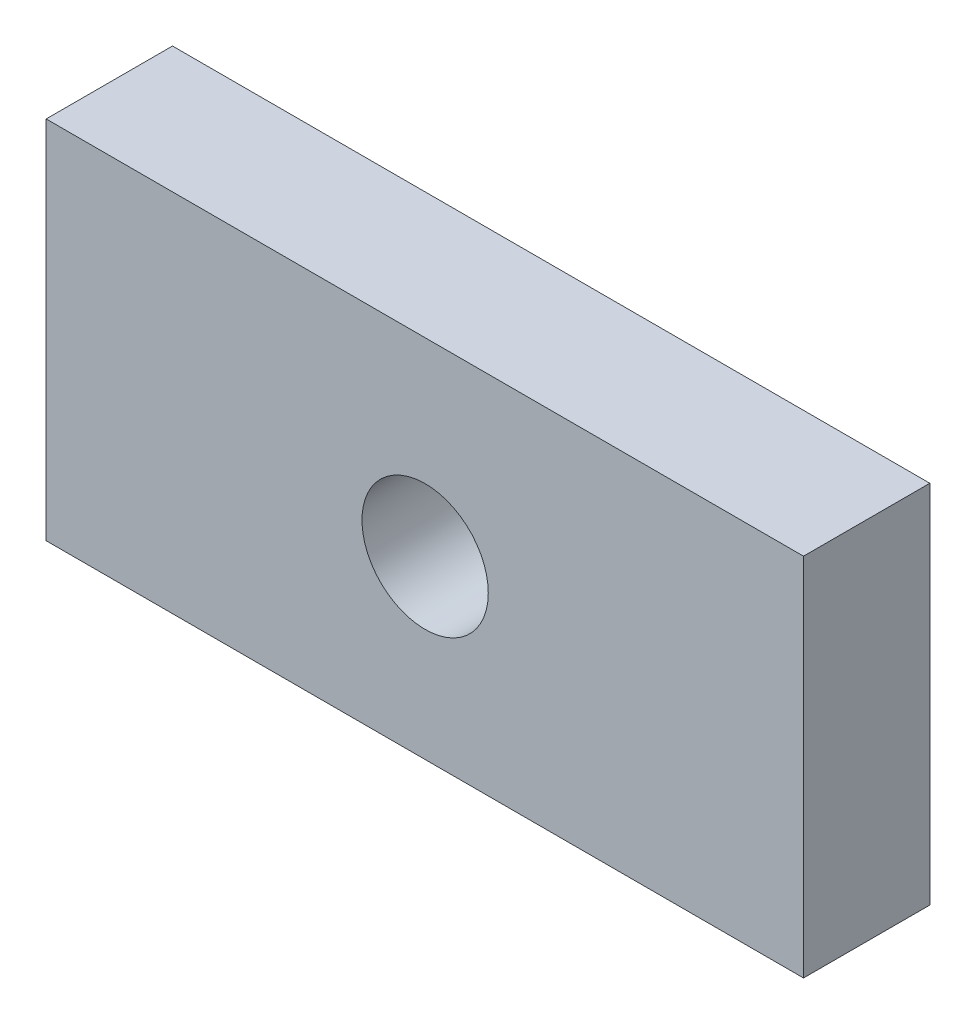
from build123d import *

# Parameters (mm, degrees)
SKETCH1_W           = 76.142586727
SKETCH1_H           = 36.728728862
BOSS_EXTRUDE1_DEPTH = 12.7
SKETCH2_R           = 6.35
CUT_EXTRUDE1_DEPTH  = 13.7


with BuildPart() as part:
    # Sketch1 → Boss-Extrude1 (new body)
    with BuildSketch(Plane.XY):
        with Locations((38.071293364, 18.364364431)):
            Rectangle(SKETCH1_W, SKETCH1_H)
    extrude(amount=BOSS_EXTRUDE1_DEPTH)

    # Sketch2 → Cut-Extrude1 (cut, through all)
    with BuildSketch(Plane.XY.offset(12.7)):
        with Locations((38.1, 17.678728862)):
            Circle(SKETCH2_R)
    extrude(amount=-CUT_EXTRUDE1_DEPTH, mode=Mode.SUBTRACT)


solid = part.part
